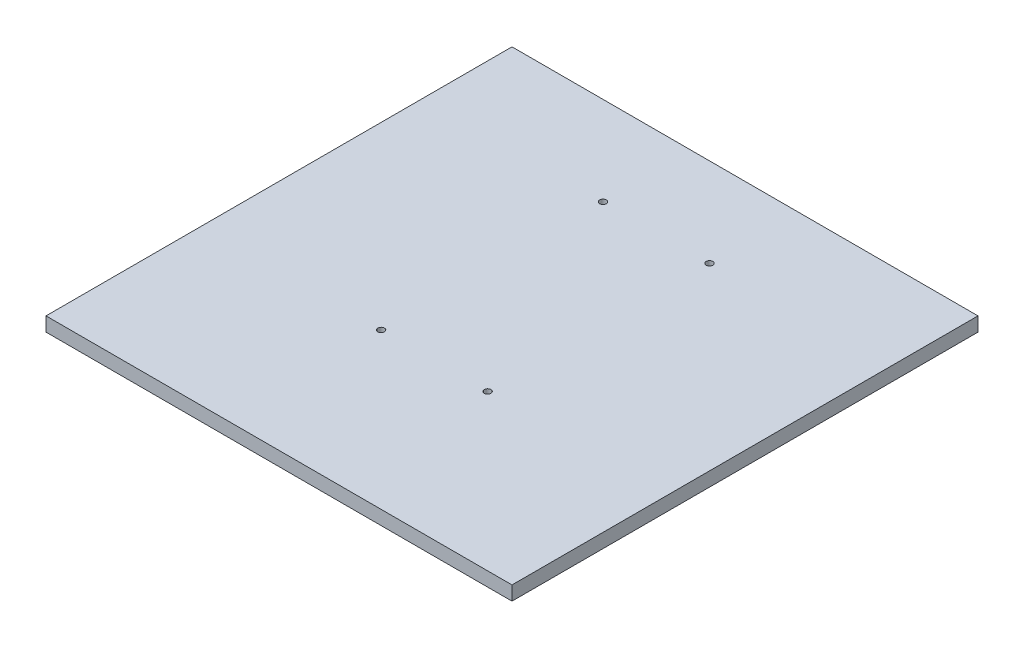
from build123d import *

# Parameters (mm, degrees)
SKETCH1_W           = 210
SKETCH1_H           = 210
BOSS_EXTRUDE1_DEPTH = 6.35
SKETCH2_R           = 1.5
CUT_EXTRUDE1_DEPTH  = 7.35


with BuildPart() as part:
    # Sketch1 → Boss-Extrude1 (new body)
    with BuildSketch(Plane(origin=(0, 0, 0), x_dir=(1, 0, 0), z_dir=(0, 1, 0))):
        Rectangle(SKETCH1_W, SKETCH1_H)
    extrude(amount=BOSS_EXTRUDE1_DEPTH)

    # Sketch2 → Cut-Extrude1 (cut, through all)
    with BuildSketch(Plane(origin=(0, 6.35, 0), x_dir=(1, 0, 0), z_dir=(0, 1, 0))):
        with Locations((24, -35)):
            Circle(SKETCH2_R)
        with Locations((-24, -35)):
            Circle(SKETCH2_R)
        with Locations((-24, 65)):
            Circle(SKETCH2_R)
        with Locations((24, 65)):
            Circle(SKETCH2_R)
    extrude(amount=-CUT_EXTRUDE1_DEPTH, mode=Mode.SUBTRACT)


solid = part.part
